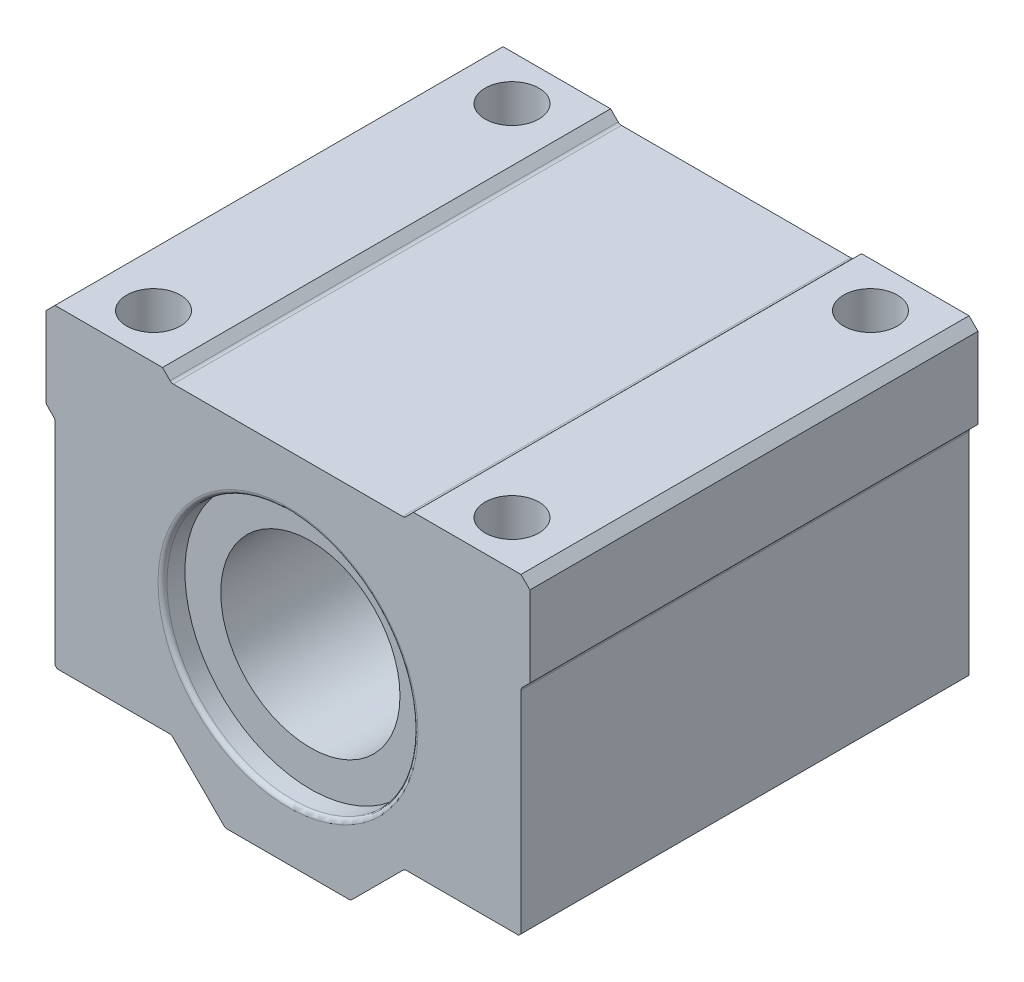
from build123d import *

# Parameters (mm, degrees)
SKETCH2_R               = 10
BOSS_EXTRUDE1_DEPTH     = 25
SKETCH3_R               = 3
CUT_EXTRUDE1_DEPTH      = 11
CUT_EXTRUDE1_DEPTH_BACK = 20
SKETCH4_R               = 2.65
CUT_EXTRUDE2_DEPTH      = 21
SKETCH5_R               = 14
CUT_EXTRUDE3_DEPTH      = 2.5
FILLET1_R               = 0.5
CHAMFER1_SIZE           = 0.25
FILLET2_R               = 0.5


with BuildPart() as part:
    # Sketch2 → Boss-Extrude1 (new body, symmetric)
    with BuildSketch(Plane.XY):
        Polygon((7, 0), (-7, 0), (-13, 6), (-26, 6), (-26, 30), (-27, 31), (-27, 40), (-26, 41), (-14, 41), (-13, 40), (13, 40), (14, 41), (26, 41), (27, 40), (27, 31), (26, 30), (26, 6), (13, 6), align=None)
        with Locations((0, 20)):
            Circle(SKETCH2_R, mode=Mode.SUBTRACT)
    extrude(amount=BOSS_EXTRUDE1_DEPTH, both=True)

    # Sketch3 → Cut-Extrude1 (cut, two sides)
    with BuildSketch(Plane(origin=(0, 40, 0), x_dir=(1, 0, 0), z_dir=(0, 1, 0))) as cut_extrude1_sk:
        with Locations((20, -20)):
            Circle(SKETCH3_R)
        with Locations((20, 20)):
            Circle(SKETCH3_R)
        with Locations((-20, -20)):
            Circle(SKETCH3_R)
        with Locations((-20, 20)):
            Circle(SKETCH3_R)
    extrude(amount=CUT_EXTRUDE1_DEPTH, mode=Mode.SUBTRACT)
    extrude(cut_extrude1_sk.sketch, amount=-CUT_EXTRUDE1_DEPTH_BACK, mode=Mode.SUBTRACT)

    # Sketch4 → Cut-Extrude2 (cut, through all)
    with BuildSketch(Plane(origin=(0, 20, 0), x_dir=(1, 0, 0), z_dir=(0, 1, 0))):
        with Locations((-20, -20)):
            Circle(SKETCH4_R)
        with Locations((20, -20)):
            Circle(SKETCH4_R)
        with Locations((20, 20)):
            Circle(SKETCH4_R)
        with Locations((-20, 20)):
            Circle(SKETCH4_R)
    extrude(amount=-CUT_EXTRUDE2_DEPTH, mode=Mode.SUBTRACT)

    # Sketch5 → Cut-Extrude3 (cut)
    with BuildSketch(Plane.XY.offset(25)):
        with Locations((0, 20)):
            Circle(SKETCH5_R)
    cut_extrude3 = extrude(amount=-CUT_EXTRUDE3_DEPTH, mode=Mode.SUBTRACT)

    # Mirror1: Cut-Extrude3 across plane
    add(cut_extrude3.mirror(Plane.XY), mode=Mode.SUBTRACT)

    # Fillet1
    fillet1_edges = [part.edges().sort_by_distance(p)[0] for p in [
        (7, 0, 0),
        (-7, 0, 0),
        (-13, 6, 0),
        (-26, 30, 0),
        (-27, 31, 0),
        (-13, 40, 0),
        (13, 40, 0),
        (26, 30, 0),
        (13, 6, 0),
        (-10, 20, -22.5),
    ]]
    fillet(fillet1_edges, radius=FILLET1_R)

    # Chamfer1
    chamfer1_edges = [part.edges().sort_by_distance(p)[0] for p in [
        (-26, 6, 0),
        (26, 6, 0),
    ]]
    chamfer(chamfer1_edges, length=CHAMFER1_SIZE)

    # Fillet2
    fillet2_edges = [part.edges().sort_by_distance(p)[0] for p in [
        (-14, 20, 25),
        (-14, 20, -25),
    ]]
    fillet(fillet2_edges, radius=FILLET2_R)


solid = part.part
